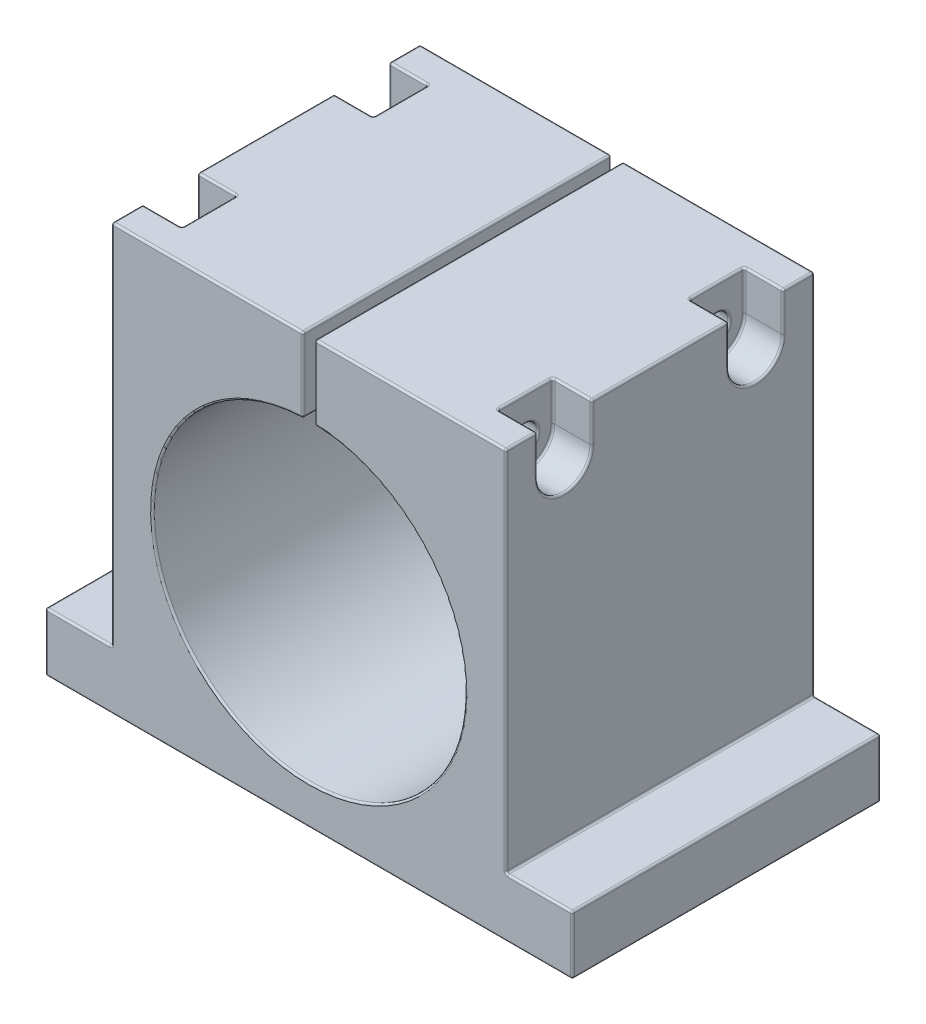
from build123d import *

# Parameters (mm, degrees)
EXTRUDE_1_DEPTH     = 39.5
CUT_EXTRUDE_1_DEPTH = 10
CUT_EXTRUDE_2_DEPTH = 10
SKETCH_4_R          = 3.25
CUT_EXTRUDE_3_DEPTH = 109
FILLET_1_R          = 0.5


with BuildPart() as part:
    # Эскиз1 → Бобышка-Вытянуть1 (new body, symmetric)
    with BuildSketch(Plane.XY):
        with BuildLine():
            Line((-67.5, -50), (67.5, -50))
            Line((67.5, -50), (67.5, -35))
            Line((67.5, -35), (50.5, -35))
            Line((50.5, -35), (50.5, 59))
            Line((50.5, 59), (1.5, 59))
            Line((1.5, 59), (1.5, 39.971865105))
            ThreePointArc((1.5, 39.971865105), (28.809720582, 27.748873851), (40, 0))
            ThreePointArc((40, 0), (-27.748873851, -28.809720582), (-1.5, 39.971865105))
            Line((-1.5, 39.971865105), (-1.5, 59))
            Line((-1.5, 59), (-50.5, 59))
            Line((-50.5, 59), (-50.5, -35))
            Line((-50.5, -35), (-67.5, -35))
            Line((-67.5, -35), (-67.5, -50))
        make_face()
    extrude(amount=EXTRUDE_1_DEPTH, both=True)

    # Эскиз2 → Вырез-Вытянуть1 (cut)
    with BuildSketch(Plane.ZY.offset(50.5)):
        with BuildLine():
            ThreePointArc((-17.5, 49), (-24.5, 56), (-31.5, 49))
            Line((-31.5, 49), (-17.5, 49))
        make_face()
        with BuildLine():
            Line((-17.5, 49), (-31.5, 49))
            ThreePointArc((-31.5, 49), (-24.5, 42), (-17.5, 49))
        make_face()
        with BuildLine():
            Line((-17.5, 59), (-31.5, 59))
            Line((-31.5, 59), (-31.5, 49))
            ThreePointArc((-31.5, 49), (-24.5, 56), (-17.5, 49))
            Line((-17.5, 49), (-17.5, 59))
        make_face()
        with BuildLine():
            ThreePointArc((31.5, 49), (24.5, 56), (17.5, 49))
            Line((17.5, 49), (31.5, 49))
        make_face()
        with BuildLine():
            Line((31.5, 49), (17.5, 49))
            ThreePointArc((17.5, 49), (24.5, 42), (31.5, 49))
        make_face()
        with BuildLine():
            ThreePointArc((31.5, 49), (24.5, 56), (17.5, 49))
            Line((17.5, 49), (31.5, 49))
        make_face()
        with BuildLine():
            Line((31.5, 49), (17.5, 49))
            ThreePointArc((17.5, 49), (24.5, 42), (31.5, 49))
        make_face()
        with BuildLine():
            Line((31.5, 59), (17.5, 59))
            Line((17.5, 59), (17.5, 49))
            ThreePointArc((17.5, 49), (24.5, 56), (31.5, 49))
            Line((31.5, 49), (31.5, 59))
        make_face()
    extrude(amount=-CUT_EXTRUDE_1_DEPTH, mode=Mode.SUBTRACT)

    # Эскиз3 → Вырез-Вытянуть2 (cut)
    with BuildSketch(Plane(origin=(50.5, 0, 0), x_dir=(0, 0, -1), z_dir=(1, 0, 0))):
        with BuildLine():
            Line((-31.5, 59), (-31.5, 49))
            ThreePointArc((-31.5, 49), (-24.5, 42), (-17.5, 49))
            Line((-17.5, 49), (-17.5, 59))
            Line((-17.5, 59), (-31.5, 59))
        make_face()
        with BuildLine():
            Line((17.5, 59), (17.5, 49))
            ThreePointArc((17.5, 49), (24.5, 42), (31.5, 49))
            Line((31.5, 49), (31.5, 59))
            Line((31.5, 59), (17.5, 59))
        make_face()
    extrude(amount=-CUT_EXTRUDE_2_DEPTH, mode=Mode.SUBTRACT)

    # Эскиз4 → Вырез-Вытянуть3 (cut, through all)
    with BuildSketch(Plane.ZY.offset(40.5)):
        with Locations((-24.5, 49)):
            Circle(SKETCH_4_R)
        with Locations((24.5, 49)):
            Circle(SKETCH_4_R)
    extrude(amount=-CUT_EXTRUDE_3_DEPTH, mode=Mode.SUBTRACT)

    # Скругление1
    fillet_1_edges = [part.edges().sort_by_distance(p)[0] for p in [
        (40.5, 49, 21.25),
        (-40.5, 49, 21.25),
        (1.5, 49.485932553, -39.5),
        (-26, 59, 39.5),
        (26, 59, -39.5),
        (50.5, 12, -39.5),
        (59, -35, -39.5),
        (67.5, -42.5, -39.5),
        (0, -50, -39.5),
        (-67.5, -42.5, -39.5),
        (-59, -35, -39.5),
        (-50.5, 12, -39.5),
        (-50.5, 12, 39.5),
        (-26, 59, -39.5),
        (-1.5, 49.485932553, -39.5),
        (0, -40, -39.5),
        (-59, -35, 39.5),
        (1.5, 39.971865105, 0),
        (1.5, 59, 0),
        (50.5, 59, 35.5),
        (50.5, -35, 0),
        (67.5, -35, 0),
        (67.5, -50, 0),
        (-67.5, -50, 0),
        (-67.5, -35, 0),
        (-50.5, -35, 0),
        (-50.5, 59, 35.5),
        (-1.5, 59, 0),
        (-1.5, 39.971865105, 0),
        (-67.5, -42.5, 39.5),
        (0, -50, 39.5),
        (67.5, -42.5, 39.5),
        (-50.5, 59, 0),
        (59, -35, 39.5),
        (-40.5, 42, 24.5),
        (-40.5, 54, 17.5),
        (-40.5, 59, 24.5),
        (-45.5, 59, 17.5),
        (50.5, 12, 39.5),
        (-50.5, 54, 31.5),
        (-45.5, 59, 31.5),
        (-40.5, 54, 31.5),
        (-50.5, 42, 24.5),
        (-50.5, 54, 17.5),
        (26, 59, 39.5),
        (1.5, 49.485932553, 39.5),
        (-50.5, 59, -35.5),
        (0, -40, 39.5),
        (-40.5, 42, -24.5),
        (-50.5, 42, -24.5),
        (-50.5, 54, -31.5),
        (-40.5, 54, -17.5),
        (-40.5, 59, -24.5),
        (-45.5, 59, -31.5),
        (-50.5, 54, -17.5),
        (-45.5, 59, -17.5),
        (-40.5, 54, -31.5),
        (50.5, 59, 0),
        (40.5, 42, 24.5),
        (40.5, 54, 31.5),
        (40.5, 59, 24.5),
        (45.5, 59, 31.5),
        (40.5, 54, 17.5),
        (45.5, 59, 17.5),
        (50.5, 42, 24.5),
        (50.5, 54, 17.5),
        (50.5, 54, 31.5),
        (50.5, 59, -35.5),
        (40.5, 42, -24.5),
        (40.5, 54, -17.5),
        (40.5, 59, -24.5),
        (45.5, 59, -17.5),
        (40.5, 54, -31.5),
        (45.5, 59, -31.5),
        (50.5, 42, -24.5),
        (50.5, 54, -31.5),
        (50.5, 54, -17.5),
        (-1.5, 49.485932553, 39.5),
        (40.5, 49, -27.75),
        (-40.5, 49, -27.75),
    ]]
    fillet(fillet_1_edges, radius=FILLET_1_R)


solid = part.part
